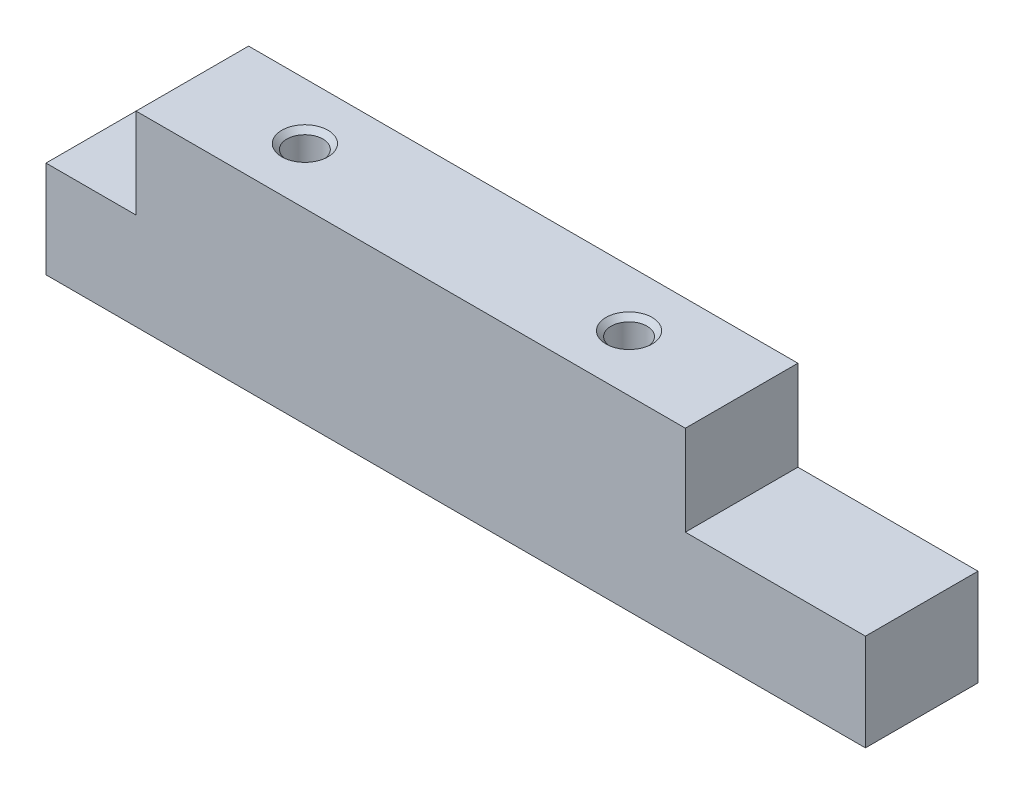
from build123d import *

# Parameters (mm, degrees)
SKETCH2_W                       = 36.4
SKETCH2_H                       = 5
BOSS_EXTRUDE1_DEPTH             = 4.3
SKETCH3_W                       = 24.4
SKETCH3_H                       = 5
BOSS_EXTRUDE2_DEPTH             = 4
M2X0_4_TAPPED_HOLE1_D           = 1.6
M2X0_4_TAPPED_HOLE1_DEPTH       = 5
M2X0_4_TAPPED_HOLE1_CSINK_D     = 2.05
M2X0_4_TAPPED_HOLE1_CSINK_ANGLE = 90
M2X0_4_TAPPED_HOLE1_TIP         = 0.480688495


with BuildPart() as part:
    # Sketch2 → Boss-Extrude1 (new body)
    with BuildSketch(Plane(origin=(0, 0, 0), x_dir=(1, 0, 0), z_dir=(0, 1, 0))):
        with Locations((18.2, 2.5)):
            Rectangle(SKETCH2_W, SKETCH2_H)
    extrude(amount=BOSS_EXTRUDE1_DEPTH)

    # Sketch3 → Boss-Extrude2 (add)
    with BuildSketch(Plane(origin=(0, 4.3, 0), x_dir=(1, 0, 0), z_dir=(0, 1, 0))):
        with Locations((16.2, 2.5)):
            Rectangle(SKETCH3_W, SKETCH3_H)
    extrude(amount=BOSS_EXTRUDE2_DEPTH)

    # M2x0.4 Tapped Hole1
    with Locations(Plane(origin=(0, 8.3, 0), x_dir=(1, 0, 0), z_dir=(0, 1, 0))):
        with Locations((9, 2.5), (23.4, 2.5)):
            CounterSinkHole(M2X0_4_TAPPED_HOLE1_D / 2, M2X0_4_TAPPED_HOLE1_CSINK_D / 2, depth=M2X0_4_TAPPED_HOLE1_DEPTH, counter_sink_angle=M2X0_4_TAPPED_HOLE1_CSINK_ANGLE)
            with Locations((0, 0, -(M2X0_4_TAPPED_HOLE1_DEPTH + M2X0_4_TAPPED_HOLE1_TIP / 2))):  # 118° drill point
                Cone(0, M2X0_4_TAPPED_HOLE1_D / 2, M2X0_4_TAPPED_HOLE1_TIP, mode=Mode.SUBTRACT)


solid = part.part
